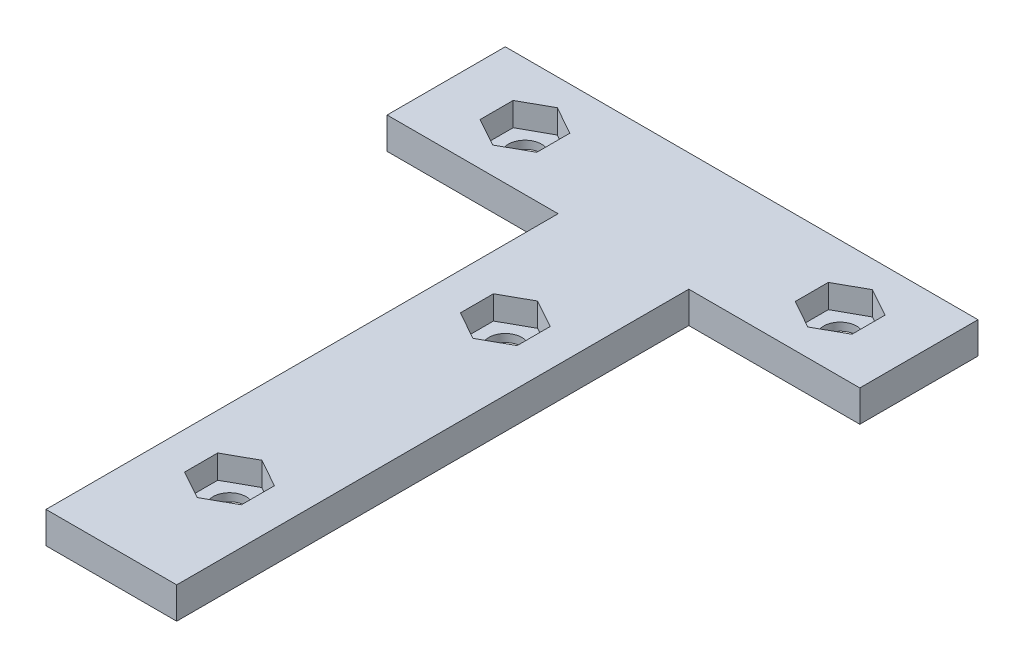
from build123d import *

# Parameters (mm, degrees)
SKETCH3_W           = 16.588644014
SKETCH3_H           = 65
SKETCH3_R           = 2.1
SKETCH3_W_2         = 60
SKETCH3_H_2         = 15
BOSS_EXTRUDE1_DEPTH = 4
CUT_EXTRUDE1_DEPTH  = 3
CUT_EXTRUDE2_DEPTH  = 3


with BuildPart() as part:
    # Sketch3 → Boss-Extrude1 (new body)
    with BuildSketch(Plane(origin=(0, 0, 0), x_dir=(1, 0, 0), z_dir=(0, 1, 0))):
        with Locations((39.448385229, -314.860414745)):
            Rectangle(SKETCH3_W, SKETCH3_H)
        with Locations((39.448385229, -332.360414745)):
            Circle(SKETCH3_R, mode=Mode.SUBTRACT)
        with Locations((39.448385229, -297.360414745)):
            Circle(SKETCH3_R, mode=Mode.SUBTRACT)
        with Locations((39.448385229, -274.860414745)):
            Rectangle(SKETCH3_W_2, SKETCH3_H_2)
        with Locations((59.448385229, -274.860414745)):
            Circle(SKETCH3_R, mode=Mode.SUBTRACT)
        with Locations((19.448385229, -274.860414745)):
            Circle(SKETCH3_R, mode=Mode.SUBTRACT)
    extrude(amount=BOSS_EXTRUDE1_DEPTH)

    # Sketch4 → Cut-Extrude1 (cut)
    with BuildSketch(Plane(origin=(0, 4, 0), x_dir=(1, 0, 0), z_dir=(0, 1, 0))):
        Polygon((15.848385229, -276.960414745), (15.848385229, -272.760414745), (19.448385229, -270.760414745), (23.048385229, -272.760414745), (23.048385229, -276.960414745), (19.448385229, -278.960414745), align=None)
        Polygon((55.848385229, -276.960414745), (55.848385229, -272.760414745), (59.448385229, -270.760414745), (63.048385229, -272.760414745), (63.048385229, -276.960414745), (59.448385229, -278.960414745), align=None)
    extrude(amount=-CUT_EXTRUDE1_DEPTH, mode=Mode.SUBTRACT)

    # Sketch5 → Cut-Extrude2 (cut)
    with BuildSketch(Plane(origin=(0, 4, 0), x_dir=(1, 0, 0), z_dir=(0, 1, 0))):
        Polygon((39.448385229, -301.460414745), (43.048385229, -299.460414745), (43.048385229, -295.260414745), (39.448385229, -293.260414745), (35.848385229, -295.260414745), (35.848385229, -299.460414745), align=None)
        Polygon((39.448385229, -328.260414745), (35.848385229, -330.260414745), (35.848385229, -334.460414745), (39.448385229, -336.460414745), (43.048385229, -334.460414745), (43.048385229, -330.260414745), align=None)
    extrude(amount=-CUT_EXTRUDE2_DEPTH, mode=Mode.SUBTRACT)


solid = part.part
